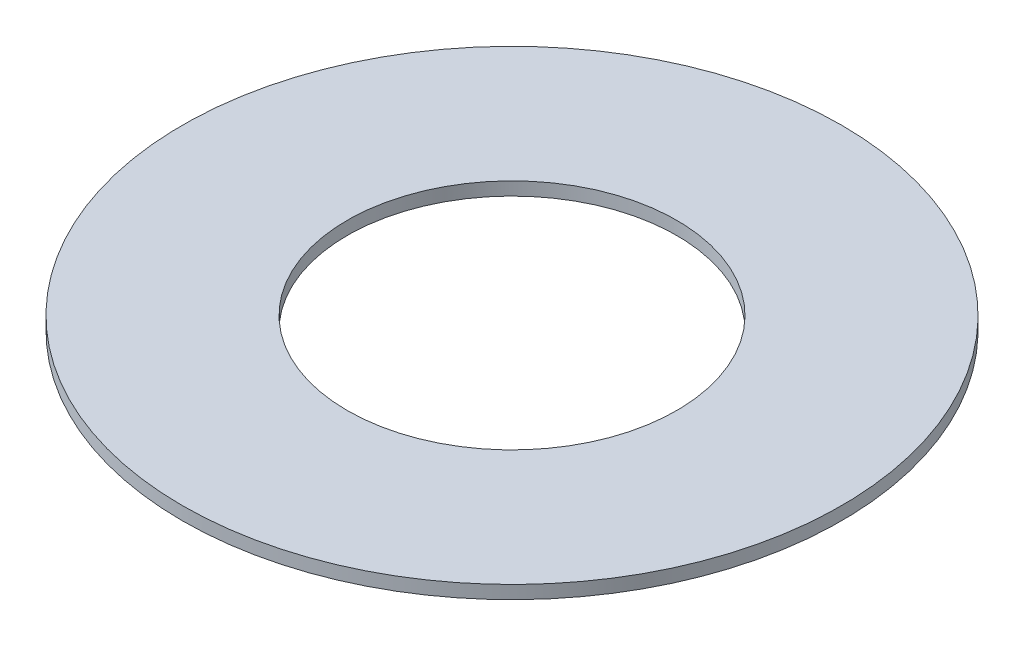
from build123d import *

# Parameters (mm, degrees)
SKETCH1_R           = 5
SKETCH1_R_2         = 2.5
BOSS_EXTRUDE1_DEPTH = 0.2


with BuildPart() as part:
    # Sketch1 → Boss-Extrude1 (new body)
    with BuildSketch(Plane(origin=(0, 0, 0), x_dir=(1, 0, 0), z_dir=(0, 1, 0))):
        Circle(SKETCH1_R)
        Circle(SKETCH1_R_2, mode=Mode.SUBTRACT)
    extrude(amount=BOSS_EXTRUDE1_DEPTH)


solid = part.part
